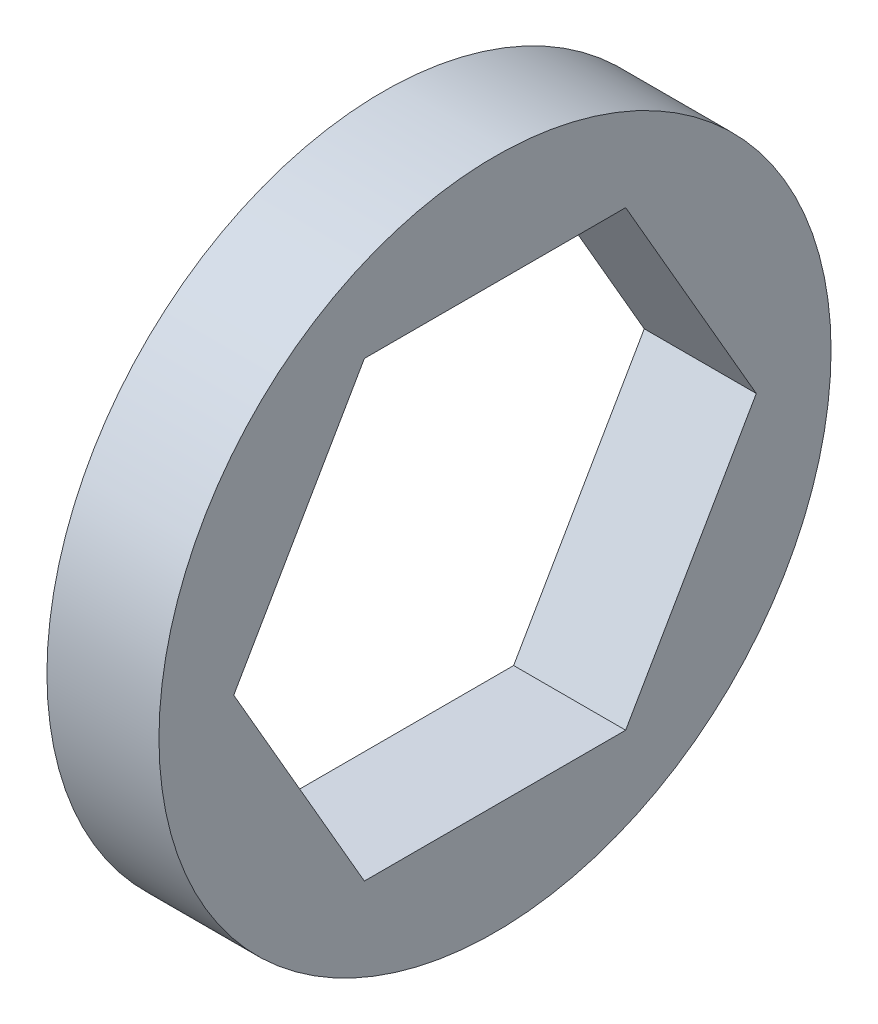
from build123d import *

# Parameters (mm, degrees)
SKETCH1_R           = 9.525
BOSS_EXTRUDE1_DEPTH = 3.175


with BuildPart() as part:
    # Sketch1 → Boss-Extrude1 (new body)
    with BuildSketch(Plane(origin=(0, 0, 0), x_dir=(0, 0, -1), z_dir=(1, 0, 0))):
        Circle(SKETCH1_R)
        Polygon((3.702835951, 6.4135), (-3.702835951, 6.4135), (-7.405671903, 0), (-3.702835951, -6.4135), (3.702835951, -6.4135), (7.405671903, 0), align=None, mode=Mode.SUBTRACT)
    extrude(amount=BOSS_EXTRUDE1_DEPTH)


solid = part.part
